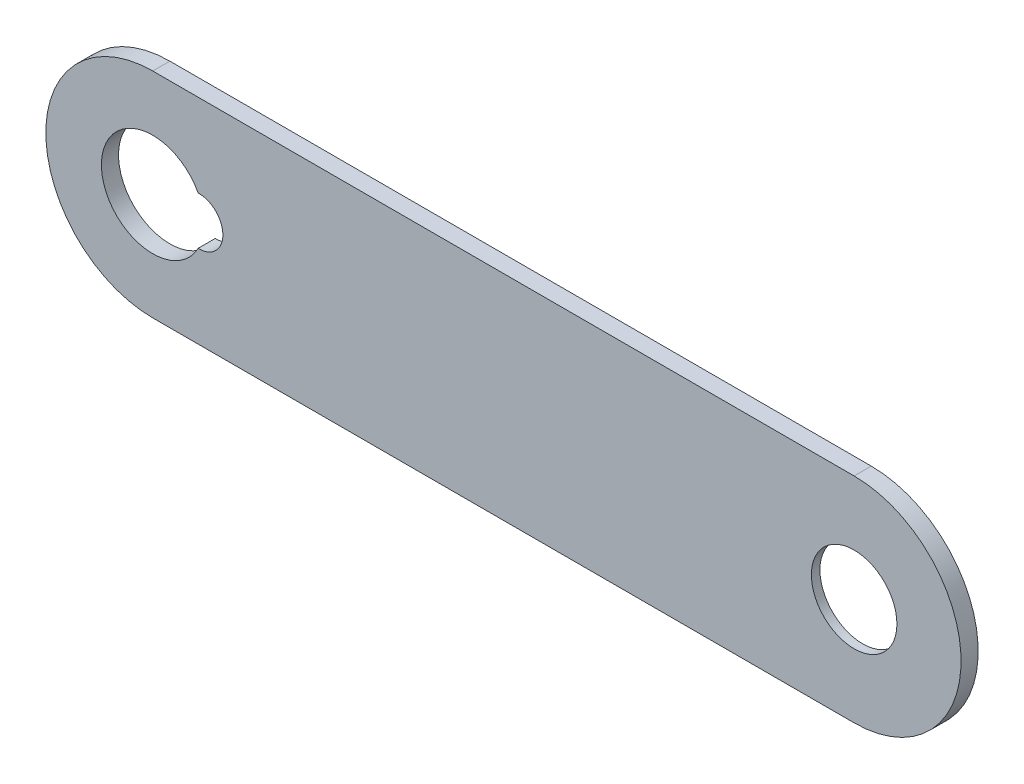
from build123d import *

# Parameters (mm, degrees)
SKETCH1_R           = 0.5
BOSS_EXTRUDE1_DEPTH = 2
CUT_EXTRUDE2_DEPTH  = 2
CUT_EXTRUDE3_DEPTH  = 1
SKETCH5_R           = 5
CUT_EXTRUDE4_DEPTH  = 10


with BuildPart() as part:
    # Sketch1 → Boss-Extrude1 (new body)
    with BuildSketch(Plane.XY):
        with BuildLine():
            Line((32.5, -3.897601476), (-49.5, -3.897601476))
            ThreePointArc((-49.5, -3.897601476), (-62, 8.602398524), (-49.5, 21.102398524))
            Line((-49.5, 21.102398524), (32.5, 21.102398524))
            ThreePointArc((32.5, 21.102398524), (45, 8.602398524), (32.5, -3.897601476))
        make_face()
        with Locations((-49.5, 8.602398524)):
            Circle(SKETCH1_R, mode=Mode.SUBTRACT)
        with Locations((32.5, 8.602398524)):
            Circle(SKETCH1_R, mode=Mode.SUBTRACT)
    extrude(amount=BOSS_EXTRUDE1_DEPTH)

    # Sketch3 → Cut-Extrude2 (cut)
    with BuildSketch(Plane(origin=(0, 0, 0), x_dir=(-1, 0, 0), z_dir=(0, 0, -1))):
        with BuildLine():
            ThreePointArc((44.192592593, 11.400867143), (41.3, 8.602398524), (44.192592593, 5.803929905))
            ThreePointArc((44.192592593, 5.803929905), (55.5, 8.602398524), (44.192592593, 11.400867143))
        make_face()
    extrude(amount=-CUT_EXTRUDE2_DEPTH, mode=Mode.SUBTRACT)

    # Sketch4 → Cut-Extrude3 (cut)
    with BuildSketch(Plane(origin=(0, 0, 0), x_dir=(-1, 0, 0), z_dir=(0, 0, -1))):
        with BuildLine():
            ThreePointArc((-33, 8.602398524), (-32.853553391, 8.955951915), (-32.5, 9.102398524))
            Line((-32.5, 9.102398524), (-32.5, 14.802398524))
            Line((-32.5, 14.802398524), (-38.5, 14.802398524))
            Line((-38.5, 14.802398524), (-38.5, 8.602398524))
            Line((-38.5, 8.602398524), (-33, 8.602398524))
        make_face()
        with BuildLine():
            Line((-32.5, 2.402398524), (-32.5, 8.102398524))
            ThreePointArc((-32.5, 8.102398524), (-32.853553391, 8.248845133), (-33, 8.602398524))
            Line((-33, 8.602398524), (-38.5, 8.602398524))
            Line((-38.5, 8.602398524), (-38.5, 2.402398524))
            Line((-38.5, 2.402398524), (-32.5, 2.402398524))
        make_face()
        with BuildLine():
            Line((-32.5, 14.802398524), (-32.5, 9.102398524))
            ThreePointArc((-32.5, 9.102398524), (-32.146446609, 8.955951915), (-32, 8.602398524))
            Line((-32, 8.602398524), (-15.7, 8.602398524))
            Line((-15.7, 8.602398524), (-15.7, 14.802398524))
            Line((-15.7, 14.802398524), (-32.5, 14.802398524))
        make_face()
        with BuildLine():
            ThreePointArc((-32, 8.602398524), (-32.146446609, 8.248845133), (-32.5, 8.102398524))
            Line((-32.5, 8.102398524), (-32.5, 2.402398524))
            Line((-32.5, 2.402398524), (-15.7, 2.402398524))
            Line((-15.7, 2.402398524), (-15.7, 8.602398524))
            Line((-15.7, 8.602398524), (-32, 8.602398524))
        make_face()
    extrude(amount=-CUT_EXTRUDE3_DEPTH, mode=Mode.SUBTRACT)

    # Sketch5 → Cut-Extrude4 (cut)
    with BuildSketch(Plane.XY.offset(2)):
        with Locations((32.5, 8.602398524)):
            Circle(SKETCH5_R)
    extrude(amount=-CUT_EXTRUDE4_DEPTH, mode=Mode.SUBTRACT)


solid = part.part
